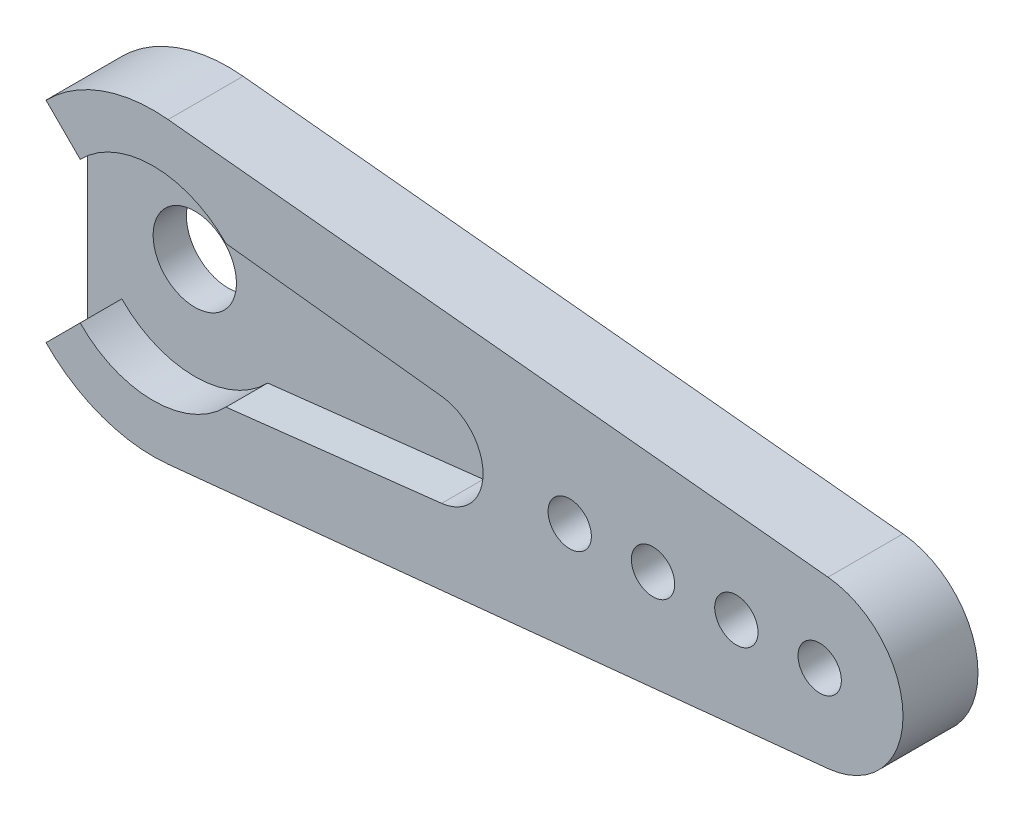
from build123d import *

# Parameters (mm, degrees)
MAIN_DEPTH            = 2.5
ORIGINALBRACKET_START = 2
ESQUISSE2_R           = 2.5
ORIGINALBRACKET_DEPTH = 2
ESQUISSE3_R           = 1.3
FIXINGHOLE_DEPTH      = 47.111278447
LPATTERN1_COUNT       = 4
LPATTERN1_PITCH       = 5


with BuildPart() as part:
    # Esquisse1 → Main (new body)
    with BuildSketch(Plane.XY):
        with BuildLine():
            Line((-4.375785644, 4.25), (-6.426543071, 6.300757427))
            ThreePointArc((-6.426543071, 6.300757427), (-3.065415215, 8.461869153), (0.9, 8.954886934))
            Line((0.9, 8.954886934), (40.5, 4.974937186))
            ThreePointArc((40.5, 4.974937186), (45, 0), (40.5, -4.974937186))
            Line((40.5, -4.974937186), (0.9, -8.954886934))
            ThreePointArc((0.9, -8.954886934), (-3.065415215, -8.461869153), (-6.426543071, -6.300757427))
            Line((-6.426543071, -6.300757427), (-4.375785644, -4.25))
            ThreePointArc((-4.375785644, -4.25), (0, -6.1), (4.375785644, -4.25))
            Line((4.375785644, -4.25), (17.31559729, -2.78215714))
            ThreePointArc((17.31559729, -2.78215714), (19.8, 0), (17.31559729, 2.78215714))
            Line((17.31559729, 2.78215714), (4.375785644, 4.25))
            ThreePointArc((4.375785644, 4.25), (0, 6.1), (-4.375785644, 4.25))
        make_face()
    extrude(amount=MAIN_DEPTH)

    # Esquisse2 → OriginalBracket (add)
    with BuildSketch(Plane(origin=(0, 0, 0), x_dir=(-1, 0, 0), z_dir=(0, 0, -1)).offset(ORIGINALBRACKET_START)):
        with BuildLine():
            Line((-0.9, -8.954886934), (-40.5, -4.974937186))
            ThreePointArc((-40.5, -4.974937186), (-45, 0), (-40.5, 4.974937186))
            Line((-40.5, 4.974937186), (-0.9, 8.954886934))
            ThreePointArc((-0.9, 8.954886934), (3.065415215, 8.461869153), (6.426543071, 6.300757427))
            Line((6.426543071, 6.300757427), (6.426543071, -6.300757427))
            ThreePointArc((6.426543071, -6.300757427), (3.065415215, -8.461869153), (-0.9, -8.954886934))
        make_face()
        Circle(ESQUISSE2_R, mode=Mode.SUBTRACT)
    extrude(amount=-ORIGINALBRACKET_DEPTH)

    # Esquisse3 → FixingHole (cut, through all)
    with BuildSketch(Plane.XY.offset(2.5)):
        with Locations((40, 0)):
            Circle(ESQUISSE3_R)
    fixinghole = extrude(amount=-FIXINGHOLE_DEPTH, mode=Mode.SUBTRACT)

    # LPattern1: FixingHole ×4
    with Locations(*[(-i * LPATTERN1_PITCH, 0, 0) for i in range(1, LPATTERN1_COUNT)]):
        add(fixinghole, mode=Mode.SUBTRACT)


solid = part.part
